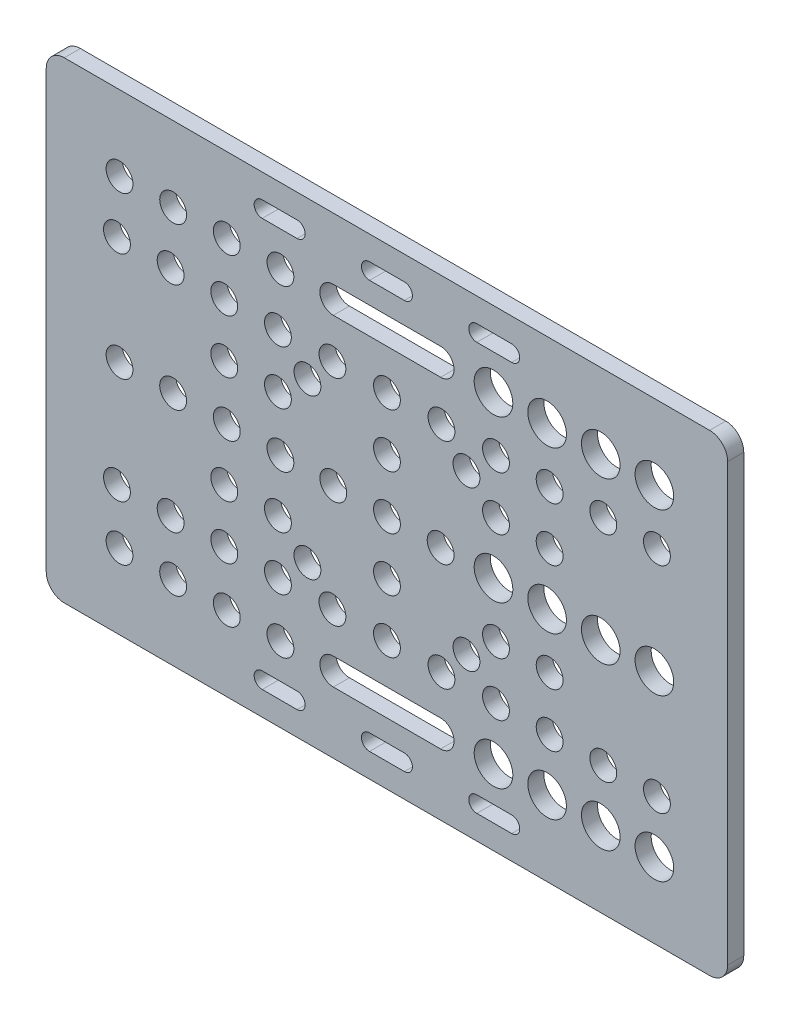
from build123d import *

# Parameters (mm, degrees)
SKETCH1_R           = 2.5
SKETCH1_R_2         = 3.6
BOSS_EXTRUDE1_DEPTH = 3


with BuildPart() as part:
    # Sketch1 → Boss-Extrude1 (new body)
    with BuildSketch(Plane.XY):
        with BuildLine():
            Line((-60.14, -44), (60.14, -44))
            ThreePointArc((60.14, -44), (62.515878785, -43.015878785), (63.5, -40.64))
            Line((63.5, -40.64), (63.5, 40.64))
            ThreePointArc((63.5, 40.64), (62.515878785, 43.015878785), (60.14, 44))
            Line((60.14, 44), (-60.14, 44))
            ThreePointArc((-60.14, 44), (-62.515878785, 43.015878785), (-63.5, 40.64))
            Line((-63.5, 40.64), (-63.5, -40.64))
            ThreePointArc((-63.5, -40.64), (-62.515878785, -43.015878785), (-60.14, -44))
        make_face()
        Circle(SKETCH1_R, mode=Mode.SUBTRACT)
        with Locations((-49.845, 0)):
            Circle(SKETCH1_R, mode=Mode.SUBTRACT)
        with Locations((49.845, 0)):
            Circle(SKETCH1_R_2, mode=Mode.SUBTRACT)
        with Locations((-19.855, -30)):
            Circle(SKETCH1_R, mode=Mode.SUBTRACT)
        with Locations((19.855, -30)):
            Circle(SKETCH1_R_2, mode=Mode.SUBTRACT)
        with Locations((-29.85, -30)):
            Circle(SKETCH1_R, mode=Mode.SUBTRACT)
        with Locations((-39.85, -30)):
            Circle(SKETCH1_R, mode=Mode.SUBTRACT)
        with Locations((-49.845, -30)):
            Circle(SKETCH1_R, mode=Mode.SUBTRACT)
        with Locations((49.845, -30)):
            Circle(SKETCH1_R_2, mode=Mode.SUBTRACT)
        with Locations((39.85, -30)):
            Circle(SKETCH1_R_2, mode=Mode.SUBTRACT)
        with Locations((29.85, -30)):
            Circle(SKETCH1_R_2, mode=Mode.SUBTRACT)
        with Locations((49.845, 30)):
            Circle(SKETCH1_R_2, mode=Mode.SUBTRACT)
        with Locations((39.85, 30)):
            Circle(SKETCH1_R_2, mode=Mode.SUBTRACT)
        with Locations((29.85, 30)):
            Circle(SKETCH1_R_2, mode=Mode.SUBTRACT)
        with Locations((19.855, 30)):
            Circle(SKETCH1_R_2, mode=Mode.SUBTRACT)
        with Locations((-19.855, 30)):
            Circle(SKETCH1_R, mode=Mode.SUBTRACT)
        with Locations((-29.85, 30)):
            Circle(SKETCH1_R, mode=Mode.SUBTRACT)
        with Locations((-39.85, 30)):
            Circle(SKETCH1_R, mode=Mode.SUBTRACT)
        with Locations((-49.845, 30)):
            Circle(SKETCH1_R, mode=Mode.SUBTRACT)
        with Locations((-50.32, -20)):
            Circle(SKETCH1_R, mode=Mode.SUBTRACT)
        with Locations((-40.32, -20)):
            Circle(SKETCH1_R, mode=Mode.SUBTRACT)
        with Locations((-30.32, -20)):
            Circle(SKETCH1_R, mode=Mode.SUBTRACT)
        with Locations((-20.32, -20)):
            Circle(SKETCH1_R, mode=Mode.SUBTRACT)
        with Locations((50.32, -20)):
            Circle(SKETCH1_R, mode=Mode.SUBTRACT)
        with Locations((40.32, -20)):
            Circle(SKETCH1_R, mode=Mode.SUBTRACT)
        with Locations((30.32, -20)):
            Circle(SKETCH1_R, mode=Mode.SUBTRACT)
        with Locations((20.32, -20)):
            Circle(SKETCH1_R, mode=Mode.SUBTRACT)
        with Locations((50.32, 20)):
            Circle(SKETCH1_R, mode=Mode.SUBTRACT)
        with Locations((40.32, 20)):
            Circle(SKETCH1_R, mode=Mode.SUBTRACT)
        with Locations((30.32, 20)):
            Circle(SKETCH1_R, mode=Mode.SUBTRACT)
        with Locations((20.32, 20)):
            Circle(SKETCH1_R, mode=Mode.SUBTRACT)
        with Locations((-20.32, 20)):
            Circle(SKETCH1_R, mode=Mode.SUBTRACT)
        with Locations((-30.32, 20)):
            Circle(SKETCH1_R, mode=Mode.SUBTRACT)
        with Locations((-40.32, 20)):
            Circle(SKETCH1_R, mode=Mode.SUBTRACT)
        with Locations((-50.32, 20)):
            Circle(SKETCH1_R, mode=Mode.SUBTRACT)
        with Locations((-39.85, 0)):
            Circle(SKETCH1_R, mode=Mode.SUBTRACT)
        with Locations((-29.85, 0)):
            Circle(SKETCH1_R, mode=Mode.SUBTRACT)
        with Locations((-19.855, 0)):
            Circle(SKETCH1_R, mode=Mode.SUBTRACT)
        with Locations((39.85, 0)):
            Circle(SKETCH1_R_2, mode=Mode.SUBTRACT)
        with Locations((29.85, 0)):
            Circle(SKETCH1_R_2, mode=Mode.SUBTRACT)
        with Locations((19.855, 0)):
            Circle(SKETCH1_R_2, mode=Mode.SUBTRACT)
        with Locations((0, -20)):
            Circle(SKETCH1_R, mode=Mode.SUBTRACT)
        with Locations((0, 20)):
            Circle(SKETCH1_R, mode=Mode.SUBTRACT)
        with Locations((-10.16, -20)):
            Circle(SKETCH1_R, mode=Mode.SUBTRACT)
        with Locations((10.16, -20)):
            Circle(SKETCH1_R, mode=Mode.SUBTRACT)
        with Locations((10.16, 20)):
            Circle(SKETCH1_R, mode=Mode.SUBTRACT)
        with Locations((-10.16, 20)):
            Circle(SKETCH1_R, mode=Mode.SUBTRACT)
        with Locations((-10, 0)):
            Circle(SKETCH1_R, mode=Mode.SUBTRACT)
        with Locations((10, 0)):
            Circle(SKETCH1_R, mode=Mode.SUBTRACT)
        with Locations((0, -10)):
            Circle(SKETCH1_R, mode=Mode.SUBTRACT)
        with Locations((0, 10)):
            Circle(SKETCH1_R, mode=Mode.SUBTRACT)
        with Locations((-30.32, -10)):
            Circle(SKETCH1_R, mode=Mode.SUBTRACT)
        with Locations((-20.32, -10)):
            Circle(SKETCH1_R, mode=Mode.SUBTRACT)
        with Locations((30.32, -10)):
            Circle(SKETCH1_R, mode=Mode.SUBTRACT)
        with Locations((20.32, -10)):
            Circle(SKETCH1_R, mode=Mode.SUBTRACT)
        with Locations((30.32, 10)):
            Circle(SKETCH1_R, mode=Mode.SUBTRACT)
        with Locations((20.32, 10)):
            Circle(SKETCH1_R, mode=Mode.SUBTRACT)
        with Locations((-30.32, 10)):
            Circle(SKETCH1_R, mode=Mode.SUBTRACT)
        with Locations((-20.32, 10)):
            Circle(SKETCH1_R, mode=Mode.SUBTRACT)
        with Locations((-14.82, -14.82)):
            Circle(SKETCH1_R, mode=Mode.SUBTRACT)
        with Locations((14.82, -14.82)):
            Circle(SKETCH1_R, mode=Mode.SUBTRACT)
        with Locations((14.82, 14.82)):
            Circle(SKETCH1_R, mode=Mode.SUBTRACT)
        with Locations((-14.82, 14.82)):
            Circle(SKETCH1_R, mode=Mode.SUBTRACT)
        with BuildLine():
            Line((-10, -27.5), (10, -27.5))
            ThreePointArc((10, -27.5), (12.5, -30), (10, -32.5))
            Line((10, -32.5), (-10, -32.5))
            ThreePointArc((-10, -32.5), (-12.5, -30), (-10, -27.5))
        make_face(mode=Mode.SUBTRACT)
        with BuildLine():
            Line((-10, 27.5), (10, 27.5))
            ThreePointArc((10, 27.5), (12.5, 30), (10, 32.5))
            Line((10, 32.5), (-10, 32.5))
            ThreePointArc((-10, 32.5), (-12.5, 30), (-10, 27.5))
        make_face(mode=Mode.SUBTRACT)
        with BuildLine():
            Line((-3.25, -36.52), (3.25, -36.52))
            ThreePointArc((3.25, -36.52), (4.75, -38.02), (3.25, -39.52))
            Line((3.25, -39.52), (-3.25, -39.52))
            ThreePointArc((-3.25, -39.52), (-4.75, -38.02), (-3.25, -36.52))
        make_face(mode=Mode.SUBTRACT)
        with BuildLine():
            Line((-23.25, -36.52), (-16.75, -36.52))
            ThreePointArc((-16.75, -36.52), (-15.25, -38.02), (-16.75, -39.52))
            Line((-16.75, -39.52), (-23.25, -39.52))
            ThreePointArc((-23.25, -39.52), (-24.75, -38.02), (-23.25, -36.52))
        make_face(mode=Mode.SUBTRACT)
        with BuildLine():
            Line((23.25, -36.52), (16.75, -36.52))
            ThreePointArc((16.75, -36.52), (15.25, -38.02), (16.75, -39.52))
            Line((16.75, -39.52), (23.25, -39.52))
            ThreePointArc((23.25, -39.52), (24.75, -38.02), (23.25, -36.52))
        make_face(mode=Mode.SUBTRACT)
        with BuildLine():
            Line((-23.25, 36.52), (-16.75, 36.52))
            ThreePointArc((-16.75, 36.52), (-15.25, 38.02), (-16.75, 39.52))
            Line((-16.75, 39.52), (-23.25, 39.52))
            ThreePointArc((-23.25, 39.52), (-24.75, 38.02), (-23.25, 36.52))
        make_face(mode=Mode.SUBTRACT)
        with BuildLine():
            Line((-3.25, 36.52), (3.25, 36.52))
            ThreePointArc((3.25, 36.52), (4.75, 38.02), (3.25, 39.52))
            Line((3.25, 39.52), (-3.25, 39.52))
            ThreePointArc((-3.25, 39.52), (-4.75, 38.02), (-3.25, 36.52))
        make_face(mode=Mode.SUBTRACT)
        with BuildLine():
            Line((23.25, 36.52), (16.75, 36.52))
            ThreePointArc((16.75, 36.52), (15.25, 38.02), (16.75, 39.52))
            Line((16.75, 39.52), (23.25, 39.52))
            ThreePointArc((23.25, 39.52), (24.75, 38.02), (23.25, 36.52))
        make_face(mode=Mode.SUBTRACT)
    extrude(amount=BOSS_EXTRUDE1_DEPTH)


solid = part.part
